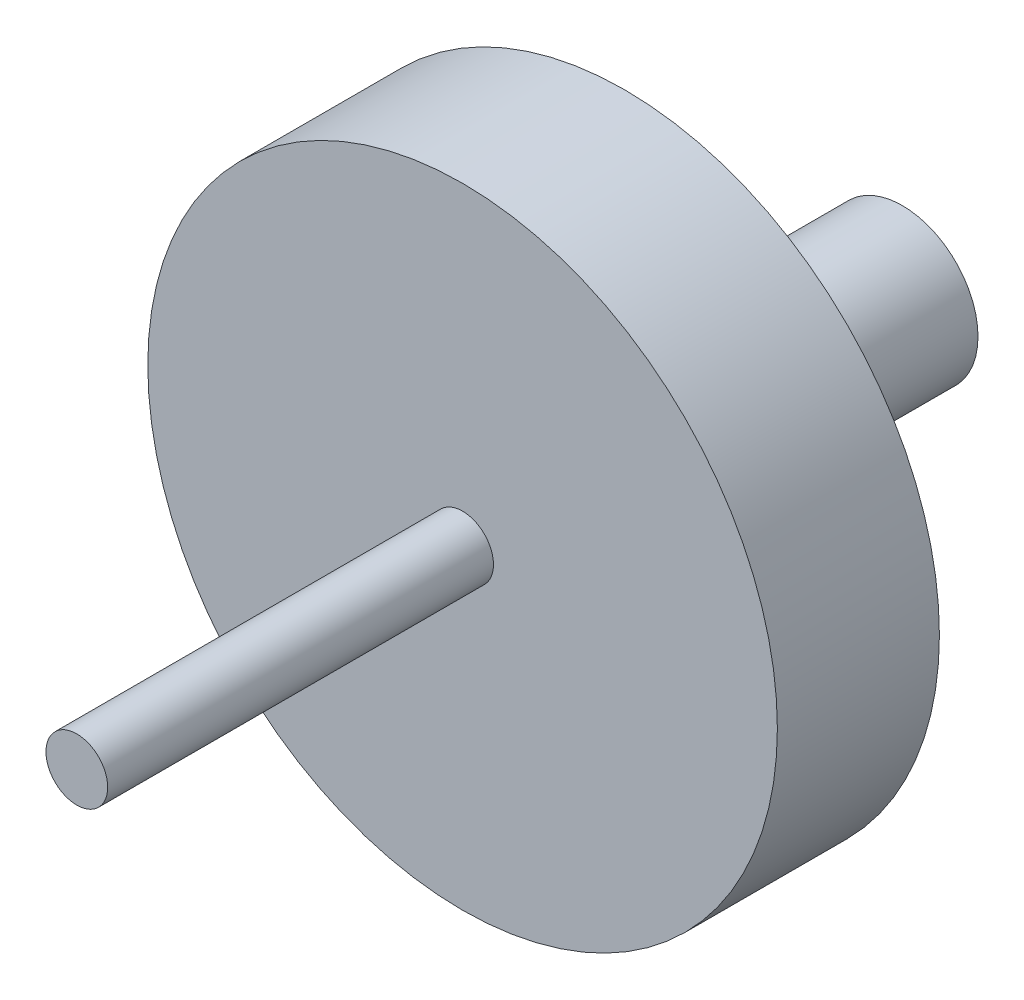
from build123d import *


with BuildPart() as part:
    # Sketch1 → Revolve1 (revolve)
    with BuildSketch(Plane(origin=(0, 0, 0), x_dir=(1, 0, 0), z_dir=(0, 1, 0))):
        Polygon((4.9, 0), (0, 0), (0, -53.5), (2, -53.5), (2, -28.5), (20.4, -28.5), (20.4, -18), (4.9, -18), align=None)
    revolve(axis=Axis((0, 0, 0), (0, 0, 1)))


solid = part.part
